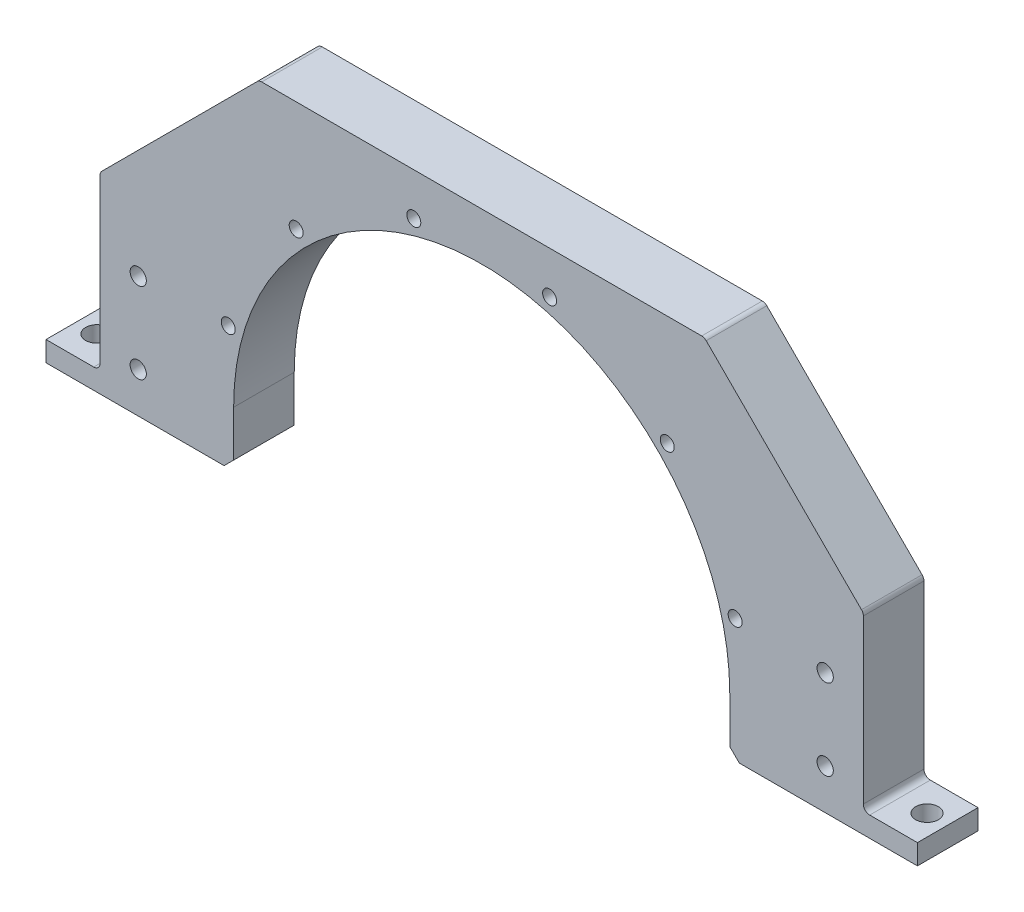
from build123d import *

# Parameters (mm, degrees)
BOSS_EXTRUDE1_DEPTH              = 19.05
TAPPED_HOLE_FOR_8_32_HELICOIL1_D = 4.3942
F_1_4_20_TAPPED_HOLE1_D          = 5.1054
F_1_4_CLEARANCE_HOLE1_D          = 7.14248
F_1_4_CLEARANCE_HOLE1_DEPTH      = 12.7
F_1_4_CLEARANCE_HOLE1_TIP        = 2.145817477
CHAMFER2_SIZE                    = 3
CHAMFER3_SIZE                    = 50
FILLET2_R                        = 2


with BuildPart() as part:
    # Sketch1 → Boss-Extrude1 (new body)
    with BuildSketch(Plane.XY):
        with BuildLine():
            Line((78, 0), (78, -17.4))
            Line((78, -17.4), (137, -17.4))
            Line((137, -17.4), (137, -11.05))
            Line((137, -11.05), (120, -11.05))
            Line((120, -11.05), (120, 93))
            Line((120, 93), (0, 93))
            Line((0, 93), (0, 78))
            ThreePointArc((0, 78), (55.154328933, 55.154328933), (78, 0))
        make_face()
    extrude(amount=BOSS_EXTRUDE1_DEPTH)

    # Tapped Hole for #8-32 Helicoil1 (through all)
    with Locations(Plane.XY.offset(19.05)):
        with Locations((21.352571221, 79.688880669), (58.336309448, 58.336309448), (79.688880669, 21.352571221)):
            Hole(TAPPED_HOLE_FOR_8_32_HELICOIL1_D / 2)

    # 1/4-20 Tapped Hole1 (through all)
    with Locations(Plane.XY.offset(19.05)):
        with Locations((108, 20.7), (108, -4.7)):
            Hole(F_1_4_20_TAPPED_HOLE1_D / 2)

    # 1/4 Clearance Hole1
    with Locations(Plane(origin=(0, -11.05, 0), x_dir=(1, 0, 0), z_dir=(0, 1, 0))):
        with Locations((130.5, -9.525)):
            Hole(F_1_4_CLEARANCE_HOLE1_D / 2, depth=F_1_4_CLEARANCE_HOLE1_DEPTH)
            with Locations((0, 0, -(F_1_4_CLEARANCE_HOLE1_DEPTH + F_1_4_CLEARANCE_HOLE1_TIP / 2))):  # 118° drill point
                Cone(0, F_1_4_CLEARANCE_HOLE1_D / 2, F_1_4_CLEARANCE_HOLE1_TIP, mode=Mode.SUBTRACT)

    # Chamfer2
    chamfer2_edges = [part.edges().sort_by_distance(p)[0] for p in [
        (78, -17.4, 9.525),
    ]]
    chamfer(chamfer2_edges, length=CHAMFER2_SIZE)

    # Chamfer3
    chamfer3_edges = [part.edges().sort_by_distance(p)[0] for p in [
        (120, 93, 9.525),
    ]]
    chamfer(chamfer3_edges, length=CHAMFER3_SIZE)

    # Fillet2
    fillet2_edges = [part.edges().sort_by_distance(p)[0] for p in [
        (120, -11.05, 9.525),
        (70, 93, 9.525),
        (120, 43, 9.525),
    ]]
    fillet(fillet2_edges, radius=FILLET2_R)

    # Mirror2: part across plane


with BuildPart() as part_1:
    add(part.part)
    add(part.part.mirror(Plane(origin=(0, 0, 0), x_dir=(0, 0, 1), z_dir=(1, 0, 0))))


solid = part_1.part
